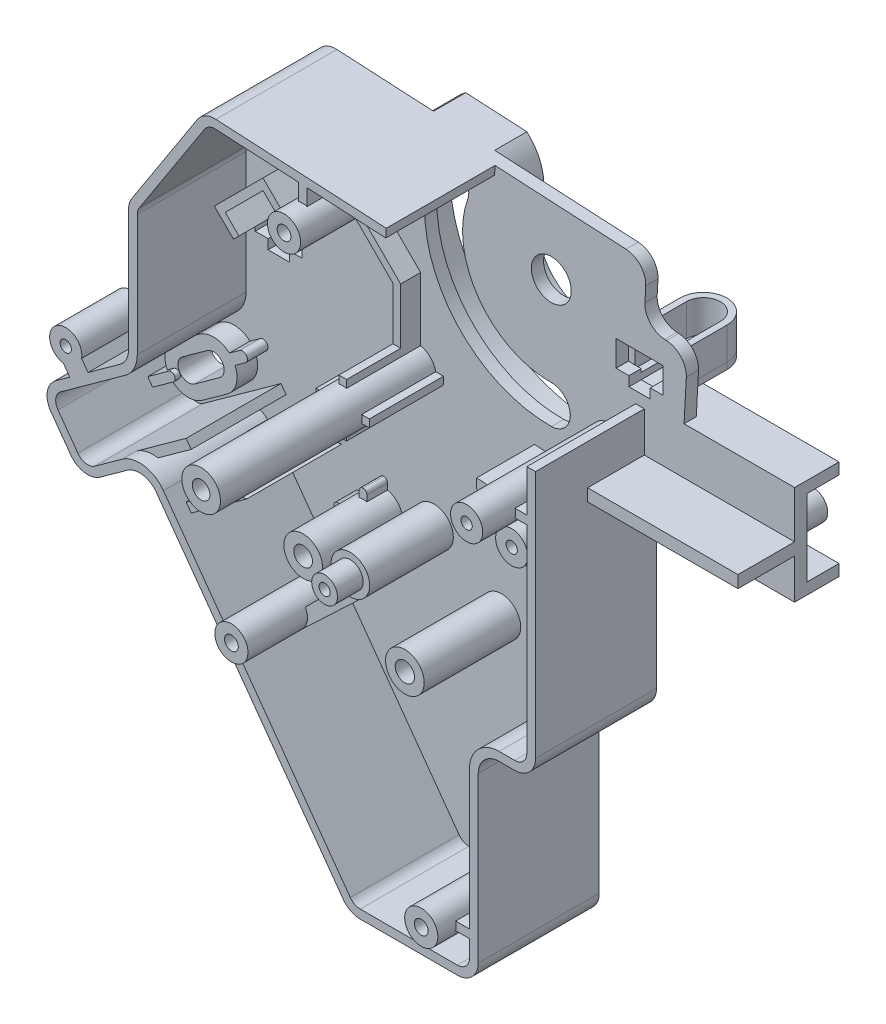
from build123d import *

# Parameters (mm, degrees)
BOSS_EXTRUDE1_DEPTH  = 1.9
BOSS_EXTRUDE3_DEPTH  = 16.9
CUT_EXTRUDE1_DEPTH   = 16.9
SKETCH7_R            = 2.575
SKETCH7_R_2          = 1.075
BOSS_EXTRUDE4_DEPTH  = 19.75
SKETCH8_R            = 6.71
SKETCH8_R_2          = 3.1
SKETCH8_R_3          = 1.075
SKETCH8_R_4          = 2.1
CUT_EXTRUDE3_DEPTH   = 1.9
SKETCH12_W           = 1.35
SKETCH12_H           = 13
BOSS_EXTRUDE9_DEPTH  = 16.9
SKETCH13_W           = 23.35
SKETCH13_H           = 1.9
BOSS_EXTRUDE10_DEPTH = 8.8
SKETCH14_R           = 3
SKETCH14_R_2         = 1.45
BOSS_EXTRUDE11_DEPTH = 12.5
BOSS_EXTRUDE12_DEPTH = 13.2
BOSS_EXTRUDE13_DEPTH = 3.2
SKETCH17_R           = 2.5
SKETCH17_R_2         = 0.875
BOSS_EXTRUDE14_DEPTH = 22
SKETCH18_R           = 2.5
SKETCH18_R_2         = 0.875
BOSS_EXTRUDE15_DEPTH = 15
BOSS_EXTRUDE16_DEPTH = 14.75
BOSS_EXTRUDE17_DEPTH = 16.9
BOSS_EXTRUDE20_DEPTH = 4
SKETCH25_R           = 3
SKETCH25_R_2         = 1.375
BOSS_EXTRUDE22_DEPTH = 33.5
BOSS_EXTRUDE23_DEPTH = 11.5
BOSS_EXTRUDE24_DEPTH = 3.1
BOSS_EXTRUDE25_DEPTH = 12
BOSS_EXTRUDE26_DEPTH = 5
BOSS_EXTRUDE27_DEPTH = 3.2
BOSS_EXTRUDE28_DEPTH = 3.2
SKETCH32_R           = 0.8765
BOSS_EXTRUDE29_DEPTH = 10.1
SKETCH37_R           = 3
SKETCH37_R_2         = 1.5
BOSS_EXTRUDE32_DEPTH = 15
SKETCH38_R           = 3
BOSS_EXTRUDE33_DEPTH = 13
SKETCH39_R           = 2
SKETCH39_R_2         = 0.875
BOSS_EXTRUDE34_DEPTH = 4
SKETCH40_R           = 1.075
BOSS_EXTRUDE35_DEPTH = 10.5
BOSS_EXTRUDE36_DEPTH = 3.2
BOSS_EXTRUDE37_DEPTH = 1
BOSS_EXTRUDE42_DEPTH = 5
BOSS_EXTRUDE43_DEPTH = 1
BOSS_EXTRUDE45_DEPTH = 5
SKETCH48_R           = 8.71
SKETCH48_R_2         = 7.71
BOSS_EXTRUDE46_DEPTH = 5
BOSS_EXTRUDE47_DEPTH = 5
SKETCH50_W           = 17.23
SKETCH50_H           = 1.9
BOSS_EXTRUDE48_DEPTH = 1.131955
SKETCH51_R           = 2.25
BOSS_EXTRUDE49_DEPTH = 5
SKETCH52_W           = 16.9
SKETCH52_H           = 1.35
CUT_EXTRUDE4_DEPTH   = 2
SKETCH53_W           = 16.9
SKETCH53_H           = 1.35
CUT_EXTRUDE5_DEPTH   = 1.5
CUT_EXTRUDE6_DEPTH   = 13.2
BOSS_EXTRUDE50_DEPTH = 9


with BuildPart() as part:
    # Sketch1 → Boss-Extrude1 (new body)
    with BuildSketch(Plane.XY):
        with BuildLine():
            Line((0, 3.242686413), (0, 28.757313587))
            ThreePointArc((0, 28.757313587), (0.949760861, 31.050239139), (3.242686413, 32))
            Line((3.242686413, 32), (5.657313587, 32))
            ThreePointArc((5.657313587, 32), (7.950239139, 32.949760861), (8.9, 35.242686413))
            Line((8.9, 35.242686413), (8.9, 59.47))
            Line((8.9, 59.47), (32.25, 59.47))
            Line((32.25, 59.47), (32.25, 73.77))
            Line((32.25, 73.77), (15.02, 73.77))
            Line((15.02, 73.77), (15.424652468, 81.316472357))
            ThreePointArc((15.424652468, 81.316472357), (14.599027591, 83.656963084), (12.360245777, 84.728134999))
            Line((12.360245777, 84.728134999), (12.066041256, 84.743910659))
            ThreePointArc((12.066041256, 84.743910659), (9.827259443, 85.815082574), (9.001634566, 88.155573301))
            Line((9.001634566, 88.155573301), (9.125570087, 90.466880061))
            ThreePointArc((9.125570087, 90.466880061), (8.29994521, 92.807370788), (6.061163396, 93.878542703))
            Line((6.061163396, 93.878542703), (-40.752001596, 96.388730489))
            ThreePointArc((-40.752001596, 96.388730489), (-42.397441336, 96.040122289), (-43.646899249, 94.91413182))
            Line((-43.646899249, 94.91413182), (-53.796907931, 79.251011133))
            ThreePointArc((-53.796907931, 79.251011133), (-54.185239465, 78.40702904), (-54.318324667, 77.487575136))
            Line((-54.318324667, 77.487575136), (-54.318324667, 58.605032351))
            ThreePointArc((-54.318324667, 58.605032351), (-54.67407234, 57.128346913), (-55.663258839, 55.975669005))
            Line((-55.663258839, 55.975669005), (-65.651963303, 48.76628643))
            ThreePointArc((-65.651963303, 48.76628643), (-66.955365193, 46.654250258), (-66.383574408, 44.239170843))
            Line((-66.383574408, 44.239170843), (-63.296647623, 39.962188864))
            ThreePointArc((-63.296647623, 39.962188864), (-61.184611451, 38.658786974), (-58.769532036, 39.23057776))
            Line((-58.769532036, 39.23057776), (-54.52498444, 42.294094914))
            ThreePointArc((-54.52498444, 42.294094914), (-52.109905026, 42.865885699), (-49.997868853, 41.56248381))
            Line((-49.997868853, 41.56248381), (-20.970710968, 1.344934172))
            ThreePointArc((-20.970710968, 1.344934172), (-19.81803306, 0.355747673), (-18.341347622, 0))
            Line((-18.341347622, 0), (-3.242686413, 0))
            ThreePointArc((-3.242686413, 0), (-0.949760861, 0.949760861), (0, 3.242686413))
        make_face()
    extrude(amount=BOSS_EXTRUDE1_DEPTH)

    # Sketch4 → Boss-Extrude3 (add)
    with BuildSketch(Plane.XY.offset(1.9)):
        with BuildLine():
            Line((15.02, 73.77), (15.424652468, 81.316472357))
            ThreePointArc((15.424652468, 81.316472357), (14.599027591, 83.656963084), (12.360245777, 84.728134999))
            Line((12.360245777, 84.728134999), (12.066041256, 84.743910659))
            ThreePointArc((12.066041256, 84.743910659), (9.827259443, 85.815082574), (9.001634566, 88.155573301))
            Line((9.001634566, 88.155573301), (9.125570087, 90.466880061))
            ThreePointArc((9.125570087, 90.466880061), (8.29994521, 92.807370788), (6.061163396, 93.878542703))
            Line((6.061163396, 93.878542703), (-40.752001596, 96.388730489))
            ThreePointArc((-40.752001596, 96.388730489), (-42.397441336, 96.040122289), (-43.646899249, 94.91413182))
            Line((-43.646899249, 94.91413182), (-53.796907931, 79.251011133))
            ThreePointArc((-53.796907931, 79.251011133), (-54.185239465, 78.40702904), (-54.318324667, 77.487575136))
            Line((-54.318324667, 77.487575136), (-54.318324667, 58.605032351))
            ThreePointArc((-54.318324667, 58.605032351), (-54.67407234, 57.128346913), (-55.663258839, 55.975669005))
            Line((-55.663258839, 55.975669005), (-65.651963303, 48.76628643))
            ThreePointArc((-65.651963303, 48.76628643), (-66.955365193, 46.654250258), (-66.383574408, 44.239170843))
            Line((-66.383574408, 44.239170843), (-63.296647623, 39.962188864))
            ThreePointArc((-63.296647623, 39.962188864), (-61.184611451, 38.658786974), (-58.769532036, 39.23057776))
            Line((-58.769532036, 39.23057776), (-54.52498444, 42.294094914))
            ThreePointArc((-54.52498444, 42.294094914), (-52.109905026, 42.865885699), (-49.997868853, 41.56248381))
            Line((-49.997868853, 41.56248381), (-20.970710968, 1.344934172))
            ThreePointArc((-20.970710968, 1.344934172), (-19.81803306, 0.355747673), (-18.341347622, 0))
            Line((-18.341347622, 0), (-3.242686413, 0))
            ThreePointArc((-3.242686413, 0), (-0.949760861, 0.949760861), (0, 3.242686413))
            Line((0, 3.242686413), (0, 28.757313587))
            ThreePointArc((0, 28.757313587), (0.949760861, 31.050239139), (3.242686413, 32))
            Line((3.242686413, 32), (5.657313587, 32))
            ThreePointArc((5.657313587, 32), (7.950239139, 32.949760861), (8.9, 35.242686413))
            Line((8.9, 35.242686413), (8.9, 59.47))
            Line((8.9, 59.47), (32.25, 59.47))
            Line((32.25, 59.47), (32.25, 73.77))
            Line((32.25, 73.77), (15.02, 73.77))
        make_face()
        with BuildLine():
            Line((5.988878341, 92.530479325), (-40.824286652, 95.040667111))
            ThreePointArc((-40.824286652, 95.040667111), (-41.784694487, 94.837191992), (-42.513976235, 94.179975539))
            Line((-42.513976235, 94.179975539), (-52.663984917, 78.516854852))
            ThreePointArc((-52.663984917, 78.516854852), (-52.890645693, 78.024240632), (-52.968324667, 77.487575136))
            Line((-52.968324667, 77.487575136), (-52.968324667, 58.605032351))
            ThreePointArc((-52.968324667, 58.605032351), (-53.472177737, 56.513571049), (-54.873183821, 54.881008571))
            Line((-54.873183821, 54.881008571), (-64.861888286, 47.671625996))
            ThreePointArc((-64.861888286, 47.671625996), (-65.622655974, 46.438875844), (-65.288913974, 45.029245861))
            Line((-65.288913974, 45.029245861), (-62.201987189, 40.752263882))
            ThreePointArc((-62.201987189, 40.752263882), (-60.969237037, 39.991496193), (-59.559607054, 40.325238194))
            Line((-59.559607054, 40.325238194), (-55.315059458, 43.388755348))
            ThreePointArc((-55.315059458, 43.388755348), (-51.894530612, 44.198594918), (-48.903208419, 42.352558828))
            Line((-48.903208419, 42.352558828), (-19.876050534, 2.13500919))
            ThreePointArc((-19.876050534, 2.13500919), (-19.203257196, 1.557642276), (-18.341347622, 1.35))
            Line((-18.341347622, 1.35), (-3.242686413, 1.35))
            ThreePointArc((-3.242686413, 1.35), (-1.904355016, 1.904355016), (-1.35, 3.242686413))
            Line((-1.35, 3.242686413), (-1.35, 28.757313587))
            ThreePointArc((-1.35, 28.757313587), (-0.004833293, 32.004833293), (3.242686413, 33.35))
            Line((3.242686413, 33.35), (5.657313587, 33.35))
            ThreePointArc((5.657313587, 33.35), (6.995644984, 33.904355016), (7.55, 35.242686413))
            Line((7.55, 35.242686413), (7.55, 60.82))
            Line((7.55, 60.82), (30.9, 60.82))
            Line((30.9, 60.82), (30.9, 72.42))
            Line((30.9, 72.42), (13.595671696, 72.42))
            Line((13.595671696, 72.42), (14.07658909, 81.388757412))
            ThreePointArc((14.07658909, 81.388757412), (13.594689582, 82.754851581), (12.287960722, 83.380071621))
            Line((12.287960722, 83.380071621), (11.993756201, 83.395847281))
            ThreePointArc((11.993756201, 83.395847281), (8.822921434, 84.912971071), (7.653571188, 88.227858356))
            Line((7.653571188, 88.227858356), (7.777506709, 90.539165117))
            ThreePointArc((7.777506709, 90.539165117), (7.295607201, 91.905259285), (5.988878341, 92.530479325))
        make_face(mode=Mode.SUBTRACT)
    extrude(amount=BOSS_EXTRUDE3_DEPTH)

    # Sketch5 → Cut-Extrude1 (cut)
    with BuildSketch(Plane.XY.offset(18.8)):
        with BuildLine():
            Line((6.061163396, 93.878542703), (-10.795037644, 94.782395924))
            Line((-10.795037644, 94.782395924), (-10.867322699, 93.434332546))
            Line((-10.867322699, 93.434332546), (5.988878341, 92.530479325))
            ThreePointArc((5.988878341, 92.530479325), (7.295607201, 91.905259285), (7.777506709, 90.539165117))
            Line((7.777506709, 90.539165117), (7.653571188, 88.227858356))
            ThreePointArc((7.653571188, 88.227858356), (8.822921434, 84.912971071), (11.993756201, 83.395847281))
            Line((11.993756201, 83.395847281), (12.287960722, 83.380071621))
            ThreePointArc((12.287960722, 83.380071621), (13.594689582, 82.754851581), (14.07658909, 81.388757412))
            Line((14.07658909, 81.388757412), (13.595671696, 72.42))
            Line((13.595671696, 72.42), (30.9, 72.42))
            Line((30.9, 72.42), (30.9, 60.82))
            Line((30.9, 60.82), (8.9, 60.82))
            Line((8.9, 60.82), (8.9, 59.47))
            Line((8.9, 59.47), (32.25, 59.47))
            Line((32.25, 59.47), (32.25, 73.77))
            Line((32.25, 73.77), (15.02, 73.77))
            Line((15.02, 73.77), (15.424652468, 81.316472357))
            ThreePointArc((15.424652468, 81.316472357), (14.599027591, 83.656963084), (12.360245777, 84.728134999))
            Line((12.360245777, 84.728134999), (12.066041256, 84.743910659))
            ThreePointArc((12.066041256, 84.743910659), (9.827259443, 85.815082574), (9.001634566, 88.155573301))
            Line((9.001634566, 88.155573301), (9.125570087, 90.466880061))
            ThreePointArc((9.125570087, 90.466880061), (8.29994521, 92.807370788), (6.061163396, 93.878542703))
        make_face()
    extrude(amount=-CUT_EXTRUDE1_DEPTH, mode=Mode.SUBTRACT)

    # Sketch7 → Boss-Extrude4 (add)
    with BuildSketch(Plane.XY.offset(1.9)):
        with Locations((-35.5, 30)):
            Circle(SKETCH7_R)
        with Locations((-35.5, 30)):
            Circle(SKETCH7_R_2, mode=Mode.SUBTRACT)
        with Locations((-6, 6.5)):
            Circle(SKETCH7_R)
        with Locations((-6, 6.5)):
            Circle(SKETCH7_R_2, mode=Mode.SUBTRACT)
        with Locations((-27.318324667, 89.259203614)):
            Circle(SKETCH7_R)
        with Locations((-27.318324667, 89.259203614)):
            Circle(SKETCH7_R_2, mode=Mode.SUBTRACT)
    extrude(amount=BOSS_EXTRUDE4_DEPTH)

    # Sketch8 → Cut-Extrude3 (cut)
    with BuildSketch(Plane.XY.offset(1.9)):
        with Locations((-8.15, 50)):
            Circle(SKETCH8_R)
        with Locations((-5.548365434, 83.985977721)):
            Circle(SKETCH8_R_2)
        with Locations((-27.318324667, 89.259203614)):
            Circle(SKETCH8_R_3)
        with Locations((-38.71, 51.2)):
            Circle(SKETCH8_R_4)
        with BuildLine():
            Line((-53.859061207, 48.245006834), (-57.751187195, 45.435851215))
            ThreePointArc((-57.751187195, 45.435851215), (-60.054752747, 45.808122279), (-59.682481683, 48.111687832))
            Line((-59.682481683, 48.111687832), (-55.790355695, 50.920843451))
            ThreePointArc((-55.790355695, 50.920843451), (-53.486790143, 50.548572387), (-53.859061207, 48.245006834))
        make_face()
        Polygon((4.524652468, 81.093910659), (11.824652468, 81.093910659), (11.824652468, 77.093910659), (9.824652468, 77.093910659), (9.824652468, 75.593910659), (6.524652468, 75.593910659), (6.524652468, 77.093910659), (4.524652468, 77.093910659), align=None)
        Polygon((-51.548324667, 71.487575136), (-44.248324667, 71.487575136), (-44.248324667, 67.487575136), (-46.248324667, 67.487575136), (-46.248324667, 65.987575136), (-49.548324667, 65.987575136), (-49.548324667, 67.487575136), (-51.548324667, 67.487575136), align=None)
        with BuildLine():
            ThreePointArc((-24.094835616, 90.255941769), (-21.614660523, 72.377545087), (-5.505398824, 64.236290641))
            ThreePointArc((-5.505398824, 64.236290641), (-2.598678354, 67.228944332), (-5.591332045, 70.135664801))
            ThreePointArc((-5.591332045, 70.135664801), (-16.813979656, 75.807335636), (-18.541813718, 88.262465459))
            ThreePointArc((-18.541813718, 88.262465459), (-20.321586512, 92.035714563), (-24.094835616, 90.255941769))
        make_face()
    extrude(amount=-CUT_EXTRUDE3_DEPTH, mode=Mode.SUBTRACT)

    # Sketch12 → Boss-Extrude9 (add)
    with BuildSketch(Plane.XY.offset(1.9)):
        with Locations((8.225, 67.32)):
            Rectangle(SKETCH12_W, SKETCH12_H)
    extrude(amount=BOSS_EXTRUDE9_DEPTH)

    # Sketch13 → Boss-Extrude10 (add)
    with BuildSketch(Plane.XY.offset(1.9)):
        with Locations((20.575, 66.645)):
            Rectangle(SKETCH13_W, SKETCH13_H)
    extrude(amount=BOSS_EXTRUDE10_DEPTH)

    # Sketch14 → Boss-Extrude11 (add)
    with BuildSketch(Plane.XY.offset(1.9)):
        with Locations((-31.6, 40)):
            Circle(SKETCH14_R)
        with Locations((-31.6, 40)):
            Circle(SKETCH14_R_2, mode=Mode.SUBTRACT)
    extrude(amount=BOSS_EXTRUDE11_DEPTH)

    # Sketch15 → Boss-Extrude12 (add)
    with BuildSketch(Plane.XY.offset(1.9)):
        with BuildLine():
            Line((-1.44, 50), (0.46, 50))
            ThreePointArc((0.46, 50), (-2.061810614, 56.088189386), (-8.15, 58.61))
            Line((-8.15, 58.61), (-8.15, 56.71))
            ThreePointArc((-8.15, 56.71), (-3.405313498, 54.744686502), (-1.44, 50))
        make_face()
    extrude(amount=BOSS_EXTRUDE12_DEPTH)

    # Sketch16 → Boss-Extrude13 (add)
    with BuildSketch(Plane.XY.offset(1.9)):
        with BuildLine():
            Line((-56.960837203, 52.542562612), (-60.852963191, 49.733406993))
            ThreePointArc((-60.852963191, 49.733406993), (-61.676471909, 44.637640771), (-56.580705687, 43.814132053))
            Line((-56.580705687, 43.814132053), (-52.688579699, 46.623287672))
            ThreePointArc((-52.688579699, 46.623287672), (-51.301306242, 48.629962984), (-51.487966358, 51.062334554))
            Line((-51.487966358, 51.062334554), (-49.866247197, 52.232816062))
            ThreePointArc((-49.866247197, 52.232816062), (-49.696310157, 53.284364646), (-50.747858741, 53.454301686))
            Line((-50.747858741, 53.454301686), (-52.369577903, 52.283820178))
            ThreePointArc((-52.369577903, 52.283820178), (-54.619336962, 53.22714283), (-56.960837203, 52.542562612))
        make_face()
        with BuildLine():
            Line((-55.790355695, 50.920843451), (-59.682481683, 48.111687832))
            ThreePointArc((-59.682481683, 48.111687832), (-60.054752747, 45.808122279), (-57.751187195, 45.435851215))
            Line((-57.751187195, 45.435851215), (-53.859061207, 48.245006834))
            ThreePointArc((-53.859061207, 48.245006834), (-53.486790143, 50.548572387), (-55.790355695, 50.920843451))
        make_face(mode=Mode.SUBTRACT)
    extrude(amount=BOSS_EXTRUDE13_DEPTH)

    # Sketch17 → Boss-Extrude14 (add)
    with BuildSketch(Plane.XY.offset(1.9)):
        with Locations((3.3, 66.645)):
            Circle(SKETCH17_R)
        with Locations((3.3, 66.645)):
            Circle(SKETCH17_R_2, mode=Mode.SUBTRACT)
    extrude(amount=BOSS_EXTRUDE14_DEPTH)

    # Sketch18 → Boss-Extrude15 (add)
    with BuildSketch(Plane.XY.offset(1.9)):
        with Locations((3.3, 59.89960035)):
            Circle(SKETCH18_R)
        with Locations((3.3, 59.89960035)):
            Circle(SKETCH18_R_2, mode=Mode.SUBTRACT)
    extrude(amount=BOSS_EXTRUDE15_DEPTH)

    # Sketch19 → Boss-Extrude16 (add)
    with BuildSketch(Plane.XY.offset(1.9)):
        with BuildLine():
            Line((-55.315059458, 43.388755348), (-47.530807482, 49.007066587))
            Line((-47.530807482, 49.007066587), (-46.740732464, 47.912406153))
            Line((-46.740732464, 47.912406153), (-51.887788674, 44.197500232))
            ThreePointArc((-51.887788674, 44.197500232), (-53.682015051, 44.134653449), (-55.315059458, 43.388755348))
        make_face()
        Polygon((-47.523612438, 40.441108521), (-41.320536644, 44.918200289), (-38.097882884, 45.579262117), (-46.73353742, 39.346448087), align=None)
    extrude(amount=BOSS_EXTRUDE16_DEPTH)

    # Sketch20 → Boss-Extrude17 (add)
    with BuildSketch(Plane.XY.offset(1.9)):
        with BuildLine():
            Line((-26.587325737, 91.728265291), (-26.587325737, 94.277261231))
            Line((-26.587325737, 94.277261231), (-27.887325737, 94.346969061))
            Line((-27.887325737, 94.346969061), (-27.887325737, 91.770550421))
            ThreePointArc((-27.887325737, 91.770550421), (-27.234611856, 91.83284251), (-26.587325737, 91.728265291))
        make_face()
        with BuildLine():
            Line((7.55, 65.995), (5.714021541, 65.995))
            ThreePointArc((5.714021541, 65.995), (5.8, 66.645), (5.714021541, 67.295))
            Line((5.714021541, 67.295), (7.55, 67.295))
            Line((7.55, 67.295), (7.55, 65.995))
        make_face()
        with BuildLine():
            Line((-3.508389075, 7.15), (-1.35, 7.15))
            Line((-1.35, 7.15), (-1.35, 5.85))
            Line((-1.35, 5.85), (-3.508389075, 5.85))
            ThreePointArc((-3.508389075, 5.85), (-3.425, 6.5), (-3.508389075, 7.15))
        make_face()
        with BuildLine():
            Line((-38.831042704, 28.397426664), (-37.90075308, 29.068866471))
            ThreePointArc((-37.90075308, 29.068866471), (-37.587963421, 28.493005058), (-37.1399401, 28.014749016))
            Line((-37.1399401, 28.014749016), (-38.070229723, 27.343309209))
            Line((-38.070229723, 27.343309209), (-38.831042704, 28.397426664))
        make_face()
    extrude(amount=BOSS_EXTRUDE17_DEPTH)

    # Sketch23 → Boss-Extrude20 (add)
    with BuildSketch(Plane.XY.offset(1.9)):
        with BuildLine():
            Line((-64.246199267, 43.584549463), (-61.002760944, 45.925512479))
            ThreePointArc((-61.002760944, 45.925512479), (-60.095295726, 45.778860241), (-60.241947964, 44.871395024))
            Line((-60.241947964, 44.871395024), (-63.485386287, 42.530432008))
            Line((-63.485386287, 42.530432008), (-64.246199267, 43.584549463))
        make_face()
    extrude(amount=BOSS_EXTRUDE20_DEPTH)

    # Sketch25 → Boss-Extrude22 (add)
    with BuildSketch(Plane.XY.offset(1.9)):
        with Locations((-26.45, 62)):
            Circle(SKETCH25_R)
        with Locations((-26.45, 62)):
            Circle(SKETCH25_R_2, mode=Mode.SUBTRACT)
    extrude(amount=BOSS_EXTRUDE22_DEPTH)

    # Sketch26 → Boss-Extrude23 (add)
    with BuildSketch(Plane.XY.offset(1.9)):
        with BuildLine():
            Line((-27.05, 64.939387691), (-27.05, 66.139387691))
            Line((-27.05, 66.139387691), (-25.85, 66.139387691))
            Line((-25.85, 66.139387691), (-25.85, 64.939387691))
            ThreePointArc((-25.85, 64.939387691), (-26.45, 65), (-27.05, 64.939387691))
        make_face()
        with BuildLine():
            Line((-27.05, 59.060612309), (-27.05, 57.860612309))
            Line((-27.05, 57.860612309), (-25.85, 57.860612309))
            Line((-25.85, 57.860612309), (-25.85, 59.060612309))
            ThreePointArc((-25.85, 59.060612309), (-26.45, 59), (-27.05, 59.060612309))
        make_face()
        with BuildLine():
            Line((-29.389387691, 62.6), (-30.589387691, 62.6))
            Line((-30.589387691, 62.6), (-30.589387691, 61.4))
            Line((-30.589387691, 61.4), (-29.389387691, 61.4))
            ThreePointArc((-29.389387691, 61.4), (-29.45, 62), (-29.389387691, 62.6))
        make_face()
        with BuildLine():
            Line((-22.310612309, 61.4), (-23.510612309, 61.4))
            ThreePointArc((-23.510612309, 61.4), (-23.45, 62), (-23.510612309, 62.6))
            Line((-23.510612309, 62.6), (-22.310612309, 62.6))
            Line((-22.310612309, 62.6), (-22.310612309, 61.4))
        make_face()
    extrude(amount=BOSS_EXTRUDE23_DEPTH)

    # Sketch27 → Boss-Extrude24 (add)
    with BuildSketch(Plane.XY.offset(1.9)):
        Polygon((-27.05, 66.139387691), (-26.45, 66.139387691), (-26.45, 74.539387691), (-33.662489168, 81.751876859), (-34.086753237, 81.327612791), (-27.05, 74.290859554), align=None)
        Polygon((-26.45, 74.539387691), (-26.45, 66.139387691), (-25.85, 66.139387691), (-25.85, 74.787915829), (-33.238225099, 82.176140928), (-33.662489168, 81.751876859), align=None)
    extrude(amount=BOSS_EXTRUDE24_DEPTH)

    # Sketch28 → Boss-Extrude25 (add)
    with BuildSketch(Plane.XY.offset(1.9)):
        Polygon((-42.077059864, 77.57994685), (-42.925588002, 76.731418713), (-45.895436483, 79.701267194), (-38.329393924, 87.267309753), (-35.359545443, 84.297461272), (-36.20807358, 83.448933134), (-38.329393924, 85.570253478), (-44.198380208, 79.701267194), align=None)
    extrude(amount=BOSS_EXTRUDE25_DEPTH)

    # Sketch29 → Boss-Extrude26 (add)
    with BuildSketch(Plane.XY.offset(1.9)):
        with BuildLine():
            Line((-40.804267658, 83.095379744), (-37.021246379, 79.312358464))
            ThreePointArc((-37.021246379, 79.312358464), (-37.021246379, 78.393119649), (-37.940485194, 78.393119649))
            Line((-37.940485194, 78.393119649), (-41.723506474, 82.176140928))
            Line((-41.723506474, 82.176140928), (-40.804267658, 83.095379744))
        make_face()
    extrude(amount=BOSS_EXTRUDE26_DEPTH)

    # Sketch30 → Boss-Extrude27 (add)
    with BuildSketch(Plane.XY.offset(1.9)):
        with BuildLine():
            Line((3.9, 64.21806778), (3.9, 62.32653257))
            ThreePointArc((3.9, 62.32653257), (3.3, 62.39960035), (2.7, 62.32653257))
            Line((2.7, 62.32653257), (2.7, 64.21806778))
            ThreePointArc((2.7, 64.21806778), (3.3, 64.145), (3.9, 64.21806778))
        make_face()
        with BuildLine():
            Line((3.9, 57.47266813), (3.9, 56.97266813))
            ThreePointArc((3.9, 56.97266813), (3.3, 56.37266813), (2.7, 56.97266813))
            Line((2.7, 56.97266813), (2.7, 57.47266813))
            ThreePointArc((2.7, 57.47266813), (3.3, 57.39960035), (3.9, 57.47266813))
        make_face()
    extrude(amount=BOSS_EXTRUDE27_DEPTH)

    # Sketch31 → Boss-Extrude28 (add)
    with BuildSketch(Plane.XY.offset(1.9)):
        with BuildLine():
            Line((-48.811142097, 42.224999598), (-45.237429649, 44.804339125))
            ThreePointArc((-45.237429649, 44.804339125), (-45.102058353, 45.641999326), (-45.939718554, 45.777370622))
            Line((-45.939718554, 45.777370622), (-49.610675252, 43.127844716))
            ThreePointArc((-49.610675252, 43.127844716), (-49.234722186, 42.760477731), (-48.903208419, 42.352558828))
            Line((-48.903208419, 42.352558828), (-48.811142097, 42.224999598))
        make_face()
    extrude(amount=BOSS_EXTRUDE28_DEPTH)

    # Sketch32 → Boss-Extrude29 (add)
    with BuildSketch(Plane.XY.offset(18.8)):
        with BuildLine():
            Line((-61.62218251, 53.789393932), (-60.61870361, 52.399059314))
            Line((-60.61870361, 52.399059314), (-63.456712143, 50.350716675))
            Line((-63.456712143, 50.350716675), (-64.460191043, 51.741051293))
            ThreePointArc((-64.460191043, 51.741051293), (-65.549152401, 56.24004548), (-61.62218251, 53.789393932))
        make_face()
        with Locations((-64.086050516, 54.212896528)):
            Circle(SKETCH32_R, mode=Mode.SUBTRACT)
    extrude(amount=-BOSS_EXTRUDE29_DEPTH)

    # Sketch37 → Boss-Extrude32 (add)
    with BuildSketch(Plane.XY.offset(1.9)):
        with Locations((-13.3, 34.85)):
            Circle(SKETCH37_R)
        with Locations((-13.3, 34.85)):
            Circle(SKETCH37_R_2, mode=Mode.SUBTRACT)
    extrude(amount=BOSS_EXTRUDE32_DEPTH)

    # Sketch38 → Boss-Extrude33 (add)
    with BuildSketch(Plane.XY.offset(1.9)):
        with Locations((-23.77, 41.68)):
            Circle(SKETCH38_R)
    extrude(amount=BOSS_EXTRUDE33_DEPTH)

    # Sketch39 → Boss-Extrude34 (add)
    with BuildSketch(Plane.XY.offset(14.9)):
        with Locations((-23.77, 41.68)):
            Circle(SKETCH39_R)
        with Locations((-23.77, 41.68)):
            Circle(SKETCH39_R_2, mode=Mode.SUBTRACT)
    extrude(amount=BOSS_EXTRUDE34_DEPTH)

    # Sketch40 → Boss-Extrude35 (add)
    with BuildSketch(Plane.XY.offset(1.9)):
        with Locations((-35.5, 30)):
            Circle(SKETCH40_R)
        with BuildLine():
            Line((-33.275769361, 31.297467944), (-25.386711494, 39.152898113))
            ThreePointArc((-25.386711494, 39.152898113), (-23.487743451, 38.693307642), (-21.70849305, 39.500507147))
            Line((-21.70849305, 39.500507147), (-33.730539868, 28.129268635))
            ThreePointArc((-33.730539868, 28.129268635), (-32.951125109, 29.634128723), (-33.275769361, 31.297467944))
        make_face()
    extrude(amount=BOSS_EXTRUDE35_DEPTH)

    # Sketch41 → Boss-Extrude36 (add)
    with BuildSketch(Plane.XY.offset(1.9)):
        with BuildLine():
            ThreePointArc((-34.539387691, 40.6), (-34.6, 40), (-34.539387691, 39.4))
            Line((-34.539387691, 39.4), (-35.51, 39.4))
            ThreePointArc((-35.51, 39.4), (-35.927193001, 39.572806999), (-36.1, 39.99))
            Line((-36.1, 39.99), (-36.1, 40.01))
            ThreePointArc((-36.1, 40.01), (-35.927193001, 40.427193001), (-35.51, 40.6))
            Line((-35.51, 40.6), (-34.539387691, 40.6))
        make_face()
        with BuildLine():
            ThreePointArc((-28.660612309, 39.4), (-28.6, 40), (-28.660612309, 40.6))
            Line((-28.660612309, 40.6), (-27.69, 40.6))
            ThreePointArc((-27.69, 40.6), (-27.272806999, 40.427193001), (-27.1, 40.01))
            Line((-27.1, 40.01), (-27.1, 39.99))
            ThreePointArc((-27.1, 39.99), (-27.272806999, 39.572806999), (-27.69, 39.4))
            Line((-27.69, 39.4), (-28.660612309, 39.4))
        make_face()
        with BuildLine():
            ThreePointArc((-32.2, 37.060612309), (-31.6, 37), (-31, 37.060612309))
            Line((-31, 37.060612309), (-31, 36.09))
            ThreePointArc((-31, 36.09), (-31.172806999, 35.672806999), (-31.59, 35.5))
            Line((-31.59, 35.5), (-31.61, 35.5))
            ThreePointArc((-31.61, 35.5), (-32.027193001, 35.672806999), (-32.2, 36.09))
            Line((-32.2, 36.09), (-32.2, 37.060612309))
        make_face()
        with BuildLine():
            ThreePointArc((-31, 42.939387691), (-31.6, 43), (-32.2, 42.939387691))
            Line((-32.2, 42.939387691), (-32.2, 43.91))
            ThreePointArc((-32.2, 43.91), (-32.027193001, 44.327193001), (-31.61, 44.5))
            Line((-31.61, 44.5), (-31.59, 44.5))
            ThreePointArc((-31.59, 44.5), (-31.172806999, 44.327193001), (-31, 43.91))
            Line((-31, 43.91), (-31, 42.939387691))
        make_face()
    extrude(amount=BOSS_EXTRUDE36_DEPTH)

    # Sketch42 → Boss-Extrude37 (add)
    with BuildSketch(Plane(origin=(0, 75.593910659, 0), x_dir=(1, 0, 0), z_dir=(0, 1, 0))):
        with BuildLine():
            Line((6.524652468, 0), (6.524652468, 8))
            ThreePointArc((6.524652468, 8), (8.174652468, 9.65), (9.824652468, 8))
            Line((9.824652468, 8), (9.824652468, 0))
            Line((9.824652468, 0), (11.824652468, 0))
            Line((11.824652468, 0), (11.824652468, 8))
            ThreePointArc((11.824652468, 8), (8.174652468, 11.65), (4.524652468, 8))
            Line((4.524652468, 8), (4.524652468, 0))
            Line((4.524652468, 0), (6.524652468, 0))
        make_face()
    extrude(amount=BOSS_EXTRUDE37_DEPTH)

    # Sketch46 → Boss-Extrude43 (add)
    with BuildSketch(Plane(origin=(0, 65.987575136, 0), x_dir=(1, 0, 0), z_dir=(0, 1, 0))):
        with BuildLine():
            Line((-49.548324667, 4), (-49.548324667, 0))
            Line((-49.548324667, 0), (-51.548324667, 0))
            Line((-51.548324667, 0), (-51.548324667, 4))
            ThreePointArc((-51.548324667, 4), (-47.898324667, 7.65), (-44.248324667, 4))
            Line((-44.248324667, 4), (-44.248324667, 0))
            Line((-44.248324667, 0), (-46.248324667, 0))
            Line((-46.248324667, 0), (-46.248324667, 4))
            ThreePointArc((-46.248324667, 4), (-47.898324667, 5.65), (-49.548324667, 4))
        make_face()
    extrude(amount=BOSS_EXTRUDE43_DEPTH)

    # Sketch48 → Boss-Extrude46 (add)
    with BuildSketch(Plane(origin=(0, 0, 0), x_dir=(-1, 0, 0), z_dir=(0, 0, -1))):
        with Locations((8.15, 50)):
            Circle(SKETCH48_R)
        with Locations((8.15, 50)):
            Circle(SKETCH48_R_2, mode=Mode.SUBTRACT)
    extrude(amount=BOSS_EXTRUDE46_DEPTH)

    # Sketch49 → Boss-Extrude47 (add)
    with BuildSketch(Plane(origin=(0, 0, 0), x_dir=(-1, 0, 0), z_dir=(0, 0, -1))):
        with BuildLine():
            Line((16.245931431, 95.07468052), (25.739752632, 95.583752573))
            ThreePointArc((25.739752632, 95.583752573), (27.449045063, 93.945696141), (28.581297329, 91.866534219))
            ThreePointArc((28.581297329, 91.866534219), (25.493282164, 69.606509015), (5.435970661, 59.47))
            Line((5.435970661, 59.47), (-32.25, 59.47))
            Line((-32.25, 59.47), (-32.25, 61.236608865))
            Line((-32.25, 61.236608865), (5.461703965, 61.236608865))
            ThreePointArc((5.461703965, 61.236608865), (24.055684692, 70.63358379), (26.918406073, 91.269573792))
            ThreePointArc((26.918406073, 91.269573792), (19.307954489, 94.85928502), (15.718243262, 87.248833436))
            ThreePointArc((15.718243262, 87.248833436), (14.372955486, 77.551296932), (5.635026904, 73.135346578))
            Line((5.635026904, 73.135346578), (-32.25, 73.135346578))
            Line((-32.25, 73.135346578), (-32.25, 74.901955442))
            Line((-32.25, 74.901955442), (5.660760208, 74.901955442))
            ThreePointArc((5.660760208, 74.901955442), (12.935358014, 78.578371707), (14.055352005, 86.651873009))
            ThreePointArc((14.055352005, 86.651873009), (13.849975817, 91.201550191), (16.245931431, 95.07468052))
        make_face()
    extrude(amount=BOSS_EXTRUDE47_DEPTH)

    # Sketch50 → Boss-Extrude48 (add)
    with BuildSketch(Plane(origin=(0, 73.77, 0), x_dir=(1, 0, 0), z_dir=(0, 1, 0))):
        with Locations((23.635, -0.95)):
            Rectangle(SKETCH50_W, SKETCH50_H)
    extrude(amount=BOSS_EXTRUDE48_DEPTH)

    # Sketch51 → Boss-Extrude49 (add)
    with BuildSketch(Plane(origin=(0, 0, 0), x_dir=(-1, 0, 0), z_dir=(0, 0, -1))):
        with Locations((-28.25, 67.185977721)):
            Circle(SKETCH51_R)
    extrude(amount=BOSS_EXTRUDE49_DEPTH)

    # Sketch52 → Cut-Extrude4 (cut)
    with BuildSketch(Plane(origin=(-15.831882393, 0.848927814, 0), x_dir=(0, 0, -1), z_dir=(0.998565465, -0.053544485, 0))):
        with Locations((-10.35, 93.393412532)):
            Rectangle(SKETCH52_W, SKETCH52_H)
    extrude(amount=-CUT_EXTRUDE4_DEPTH, mode=Mode.SUBTRACT)

    # Sketch53 → Cut-Extrude5 (cut)
    with BuildSketch(Plane(origin=(-17.829013323, 0.956016785, 0), x_dir=(0, 0, -1), z_dir=(0.998565465, -0.053544485, 0))):
        with Locations((-10.35, 93.393412532)):
            Rectangle(SKETCH53_W, SKETCH53_H)
    extrude(amount=-CUT_EXTRUDE5_DEPTH, mode=Mode.SUBTRACT)

    # Sketch54 → Cut-Extrude6 (cut)
    with BuildSketch(Plane.XY.offset(15.1)):
        with BuildLine():
            Line((-1.44, 50), (0.46, 50))
            ThreePointArc((0.46, 50), (-2.061810614, 56.088189386), (-8.15, 58.61))
            Line((-8.15, 58.61), (-8.15, 56.71))
            ThreePointArc((-8.15, 56.71), (-3.405313498, 54.744686502), (-1.44, 50))
        make_face()
    extrude(amount=-CUT_EXTRUDE6_DEPTH, mode=Mode.SUBTRACT)

    # Sketch55 → Boss-Extrude50 (add)
    with BuildSketch(Plane.XY.offset(1.9)):
        with BuildLine():
            Line((-8.15, 60.5), (-8.15, 59))
            ThreePointArc((-8.15, 59), (-1.786038969, 56.363961031), (0.85, 50))
            Line((0.85, 50), (2.35, 50))
            ThreePointArc((2.35, 50), (-0.725378798, 57.424621202), (-8.15, 60.5))
        make_face()
    extrude(amount=BOSS_EXTRUDE50_DEPTH)


with BuildPart() as body_2:
    # Sketch44 → Boss-Extrude42 (new body)
    with BuildSketch(Plane(origin=(0, 76.593910659, 0), x_dir=(1, 0, 0), z_dir=(0, 1, 0))):
        with BuildLine():
            Line((5.524652468, 8), (5.524652468, 0))
            Line((5.524652468, 0), (4.524652468, 0))
            Line((4.524652468, 0), (4.524652468, 8))
            ThreePointArc((4.524652468, 8), (8.174652468, 11.65), (11.824652468, 8))
            Line((11.824652468, 8), (11.824652468, 0))
            Line((11.824652468, 0), (10.824652468, 0))
            Line((10.824652468, 0), (10.824652468, 8))
            ThreePointArc((10.824652468, 8), (8.174652468, 10.65), (5.524652468, 8))
        make_face()
    extrude(amount=BOSS_EXTRUDE42_DEPTH)


with BuildPart() as body_3:
    # Sketch47 → Boss-Extrude45 (new body)
    with BuildSketch(Plane(origin=(0, 66.987575136, 0), x_dir=(1, 0, 0), z_dir=(0, 1, 0))):
        with BuildLine():
            Line((-51.548324667, 0), (-50.548324667, 0))
            Line((-50.548324667, 0), (-50.548324667, 4))
            ThreePointArc((-50.548324667, 4), (-47.898324667, 6.65), (-45.248324667, 4))
            Line((-45.248324667, 4), (-45.248324667, 0))
            Line((-45.248324667, 0), (-44.248324667, 0))
            Line((-44.248324667, 0), (-44.248324667, 4))
            ThreePointArc((-44.248324667, 4), (-47.898324667, 7.65), (-51.548324667, 4))
            Line((-51.548324667, 4), (-51.548324667, 0))
        make_face()
    extrude(amount=BOSS_EXTRUDE45_DEPTH)


solid = Compound([part.part, body_2.part, body_3.part])
